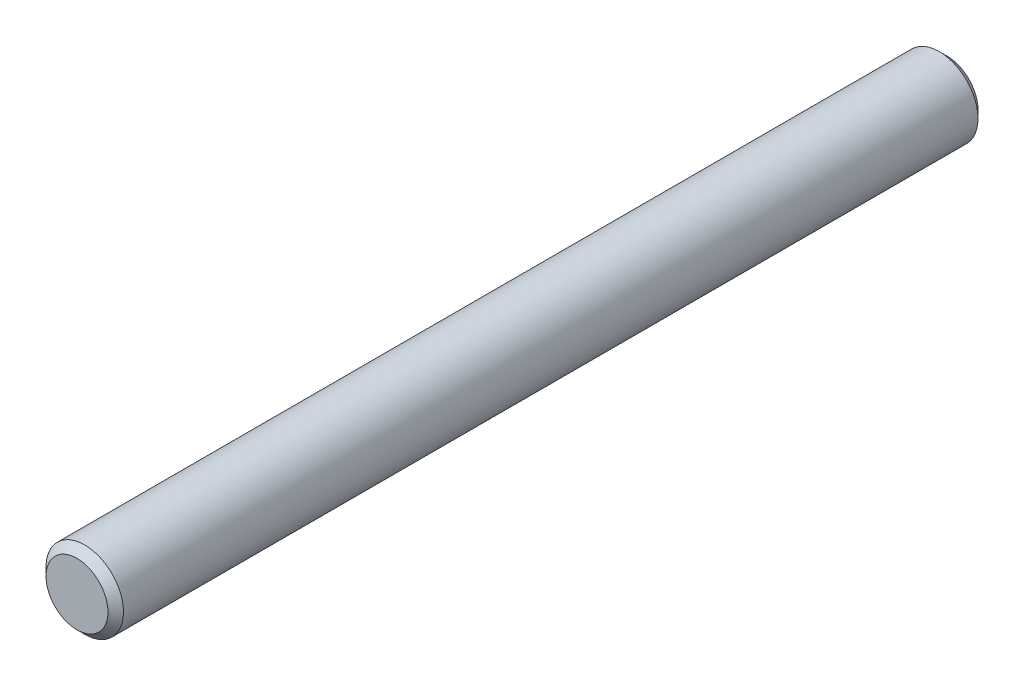
from build123d import *

# Parameters (mm, degrees)
SKETCH1_R      = 4.7625
EXTRUDE1_DEPTH = 53.49875
CHAMFER1_SIZE  = 0.9525


with BuildPart() as part:
    # Sketch1 → Extrude1 (new body, symmetric)
    with BuildSketch(Plane.XY):
        Circle(SKETCH1_R)
    extrude(amount=EXTRUDE1_DEPTH, both=True)

    # Chamfer1
    chamfer1_edges = [part.edges().sort_by_distance(p)[0] for p in [
        (-4.7625, 0, -53.49875),
        (-4.7625, 0, 53.49875),
    ]]
    chamfer(chamfer1_edges, length=CHAMFER1_SIZE)


solid = part.part
